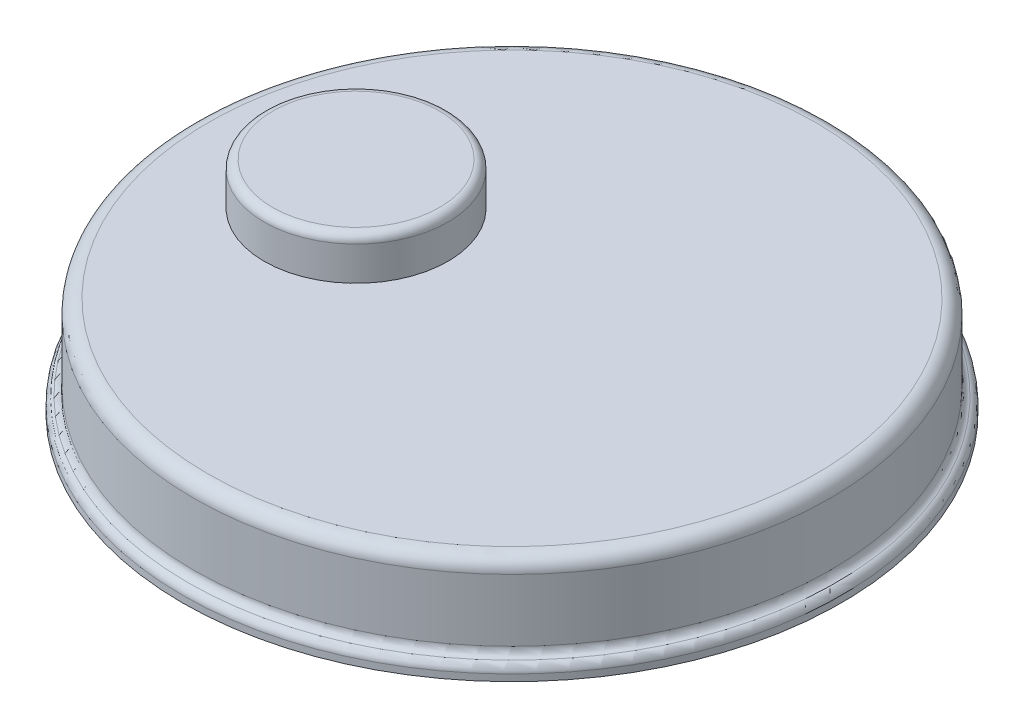
from build123d import *

# Parameters (mm, degrees)
FILLET2_R           = 3
FILLET3_R           = 3
FILLET4_R           = 5
SKETCH4_R           = 32.5
BOSS_EXTRUDE3_DEPTH = 15
FILLET6_R           = 3


with BuildPart() as part:
    # Sketch1 → Revolve1 (revolve)
    with BuildSketch(Plane.XY):
        Polygon((-20.491071429, 41.439732143), (92.008928571, 41.439732143), (92.008928571, 11.439732143), (96.008928571, 11.439732143), (96.008928571, 6.439732143), (-20.491071429, 6.439732143), align=None)
    revolve(axis=Axis((-20.491071429, 6.439732143, 0), (0, 1, 0)))

    # Fillet2
    fillet2_edges = [part.edges().sort_by_distance(p)[0] for p in [
        (-132.991071429, 11.439732143, 0),
    ]]
    fillet(fillet2_edges, radius=FILLET2_R)

    # Fillet3
    fillet3_edges = [part.edges().sort_by_distance(p)[0] for p in [
        (-136.991071429, 11.439732143, 0),
    ]]
    fillet(fillet3_edges, radius=FILLET3_R)

    # Fillet4
    fillet4_edges = [part.edges().sort_by_distance(p)[0] for p in [
        (-132.991071429, 41.439732143, 0),
    ]]
    fillet(fillet4_edges, radius=FILLET4_R)

    # Sketch4 → Boss-Extrude3 (add)
    with BuildSketch(Plane(origin=(0, 41.439732143, 0), x_dir=(1, 0, 0), z_dir=(0, 1, 0))):
        with Locations((-75.608010417, 0)):
            Circle(SKETCH4_R)
    extrude(amount=BOSS_EXTRUDE3_DEPTH)

    # Fillet6
    fillet6_edges = [part.edges().sort_by_distance(p)[0] for p in [
        (-108.108010417, 56.439732143, 0),
    ]]
    fillet(fillet6_edges, radius=FILLET6_R)


solid = part.part
